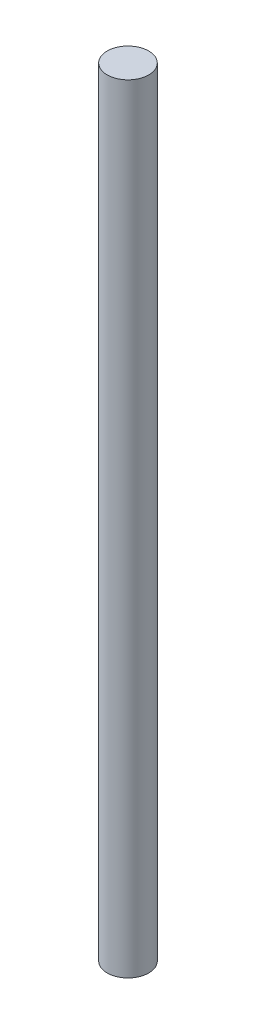
from build123d import *

# Parameters (mm, degrees)
SKETCH1_R           = 2
BOSS_EXTRUDE1_DEPTH = 75


with BuildPart() as part:
    # Sketch1 → Boss-Extrude1 (new body)
    with BuildSketch(Plane(origin=(0, 0, 0), x_dir=(1, 0, 0), z_dir=(0, 1, 0))):
        Circle(SKETCH1_R)
    extrude(amount=BOSS_EXTRUDE1_DEPTH)


solid = part.part
